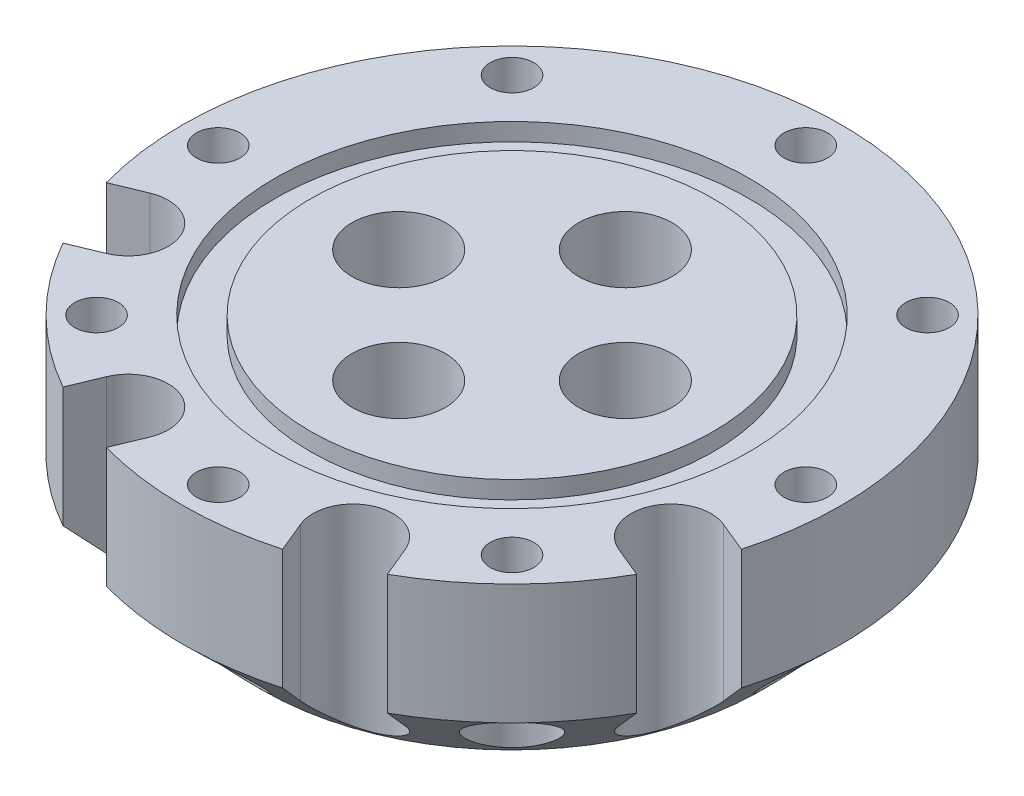
from build123d import *

# Parameters (mm, degrees)
SKETCH1_R           = 24.675
BOSS_EXTRUDE1_DEPTH = 15
SKETCH2_R           = 3.5
CUT_EXTRUDE1_DEPTH  = 15
SKETCH3_R           = 17.7546
SKETCH3_R_2         = 15.0876
CUT_EXTRUDE2_DEPTH  = 1.3208
CHAMFER1_SIZE       = 6
CIRPATTERN1_COUNT   = 8
CUT_EXTRUDE3_DEPTH  = 38.983039108
CHAMFER2_SIZE       = 0.3


with BuildPart() as part:
    # Sketch1 → Boss-Extrude1 (new body)
    with BuildSketch(Plane(origin=(0, 0, 0), x_dir=(1, 0, 0), z_dir=(0, 1, 0))):
        with Locations(Location((0, 0, 0), (0, 0, 270))):
            Circle(SKETCH1_R)
    extrude(amount=-BOSS_EXTRUDE1_DEPTH)

    # Sketch2 → Cut-Extrude1 (cut)
    with BuildSketch(Plane.XZ.offset(15)):
        with Locations(Location((0, 8.485281374, 0), (0, 0, 270))):
            Circle(SKETCH2_R)
        with Locations(Location((-8.485281374, 0, 0), (0, 0, 270))):
            Circle(SKETCH2_R)
        with Locations(Location((0, -8.485281374, 0), (0, 0, 270))):
            Circle(SKETCH2_R)
        with Locations(Location((8.485281374, 0, 0), (0, 0, 270))):
            Circle(SKETCH2_R)
    extrude(amount=-CUT_EXTRUDE1_DEPTH, mode=Mode.SUBTRACT)

    # Sketch3 → Cut-Extrude2 (cut)
    with BuildSketch(Plane(origin=(0, 0, 0), x_dir=(1, 0, 0), z_dir=(0, 1, 0))):
        with Locations(Location((0, 0, 0), (0, 0, 270))):
            Circle(SKETCH3_R)
        with Locations(Location((0, 0, 0), (0, 0, 270))):
            Circle(SKETCH3_R_2, mode=Mode.SUBTRACT)
    extrude(amount=-CUT_EXTRUDE2_DEPTH, mode=Mode.SUBTRACT)

    # Chamfer1
    chamfer1_edges = [part.edges().sort_by_distance(p)[0] for p in [
        (0, -15, -24.675),
    ]]
    chamfer(chamfer1_edges, length=CHAMFER1_SIZE)

    # Sketch7 → CBORE for #4 Button Head Cap Screw1 (revolve, cut)
    with BuildSketch(Plane(origin=(0, -15, 22), x_dir=(0, 0, -1), z_dir=(1, 0, 0))):
        Polygon((0, 0), (0, 15), (1.63195, 15), (1.63195, 5.999988), (2.794, 5.999988), (2.794, 0), align=None)
    cbore_for_4_button_head_cap_screw1 = revolve(axis=Axis((0, -21.35, 22), (0, 1, 0)), mode=Mode.SUBTRACT)

    # CirPattern1: CBORE for #4 Button Head Cap Screw1 ×8 about axis
    cirpattern1_axis = Axis((0, 0, 0), (0, 1, 0))
    for i in range(1, CIRPATTERN1_COUNT):
        add(cbore_for_4_button_head_cap_screw1.rotate(cirpattern1_axis, i * 360 / CIRPATTERN1_COUNT), mode=Mode.SUBTRACT)

    # Sketch8 → Cut-Extrude3 (cut, through all)
    with BuildSketch(Plane.XZ.offset(15)):
        with BuildLine():
            ThreePointArc((19.177299418, 11.19067411), (17.553711118, 7.270985215), (21.473400012, 5.647396914))
            Line((21.473400012, 5.647396914), (23.775661806, 6.601024973))
            ThreePointArc((23.775661806, 6.601024973), (22.796727465, 9.442713694), (21.479561212, 12.144302169))
            Line((21.479561212, 12.144302169), (19.177299418, 11.19067411))
        make_face()
        with BuildLine():
            Line((11.19067411, 19.177299418), (12.144302169, 21.479561212))
            ThreePointArc((12.144302169, 21.479561212), (9.442713694, 22.796727465), (6.601024973, 23.775661806))
            Line((6.601024973, 23.775661806), (5.647396914, 21.473400012))
            ThreePointArc((5.647396914, 21.473400012), (7.270985215, 17.553711118), (11.19067411, 19.177299418))
        make_face()
        with BuildLine():
            ThreePointArc((-6.601024973, 23.775661806), (-9.442713694, 22.796727465), (-12.144302169, 21.479561212))
            Line((-12.144302169, 21.479561212), (-11.19067411, 19.177299418))
            ThreePointArc((-11.19067411, 19.177299418), (-7.270985215, 17.553711118), (-5.647396914, 21.473400012))
            Line((-5.647396914, 21.473400012), (-6.601024973, 23.775661806))
        make_face()
        with BuildLine():
            ThreePointArc((-21.479561212, 12.144302169), (-22.796727465, 9.442713694), (-23.775661806, 6.601024973))
            Line((-23.775661806, 6.601024973), (-21.473400012, 5.647396914))
            ThreePointArc((-21.473400012, 5.647396914), (-17.553711118, 7.270985215), (-19.177299418, 11.19067411))
            Line((-19.177299418, 11.19067411), (-21.479561212, 12.144302169))
        make_face()
    extrude(amount=-CUT_EXTRUDE3_DEPTH, mode=Mode.SUBTRACT)

    # Chamfer2
    chamfer2_edges = [part.edges().sort_by_distance(p)[0] for p in [
        (0, -15, 11.985281374),
        (-8.485281374, -15, 3.5),
        (0, -15, -4.985281374),
        (8.485281374, -15, 3.5),
    ]]
    chamfer(chamfer2_edges, length=CHAMFER2_SIZE)


solid = part.part
